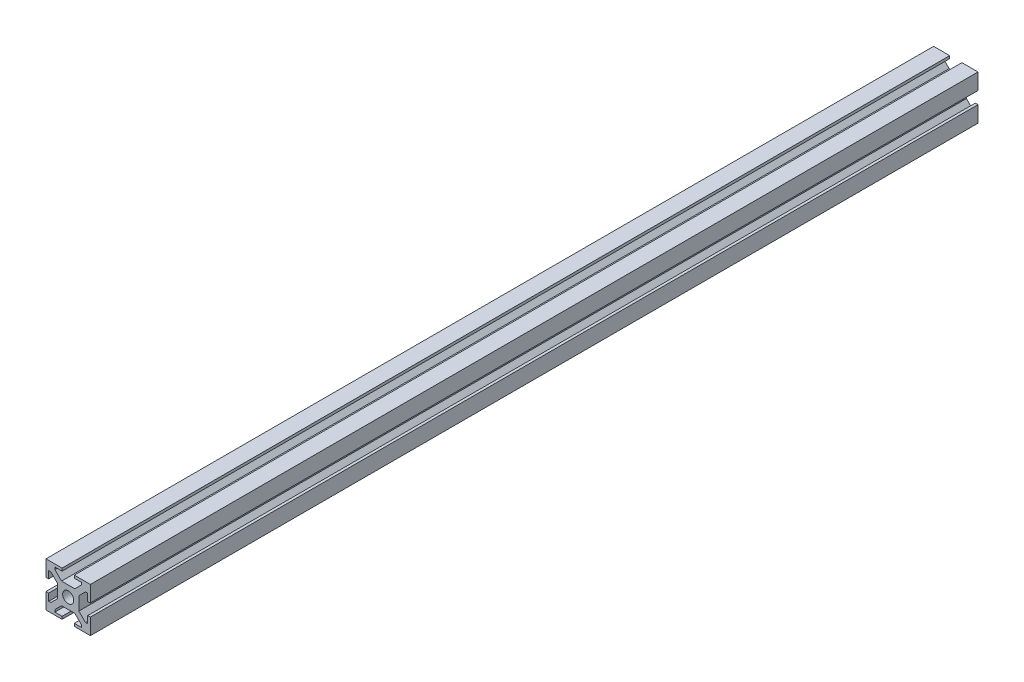
from build123d import *

# Parameters (mm, degrees)
ESQUISSE1_W             = 20
ESQUISSE1_H             = 20
BOSS_EXTRU_1_DEPTH      = 400
ESQUISSE2_W             = 1.2
ESQUISSE2_H             = 5.5
ESQUISSE2_W_2           = 5.5
ESQUISSE2_H_2           = 1.2
ENL_V_MAT_EXTRU_1_DEPTH = 401
ENL_V_MAT_EXTRU_2_DEPTH = 401
ESQUISSE4_R             = 2.5
ENL_V_MAT_EXTRU_3_DEPTH = 401


with BuildPart() as part:
    # Esquisse1 → Boss.-Extru.1 (new body)
    with BuildSketch(Plane.XY):
        with Locations((-12.505109137, -9.909560068)):
            Rectangle(ESQUISSE1_W, ESQUISSE1_H)
    extrude(amount=BOSS_EXTRU_1_DEPTH)

    # Esquisse2 → Enlèv. mat.-Extru.1 (cut, through all)
    with BuildSketch(Plane.XY.offset(400)):
        with Locations((-21.905109137, -9.909560068)):
            Rectangle(ESQUISSE2_W, ESQUISSE2_H)
        with Locations((-12.505109137, -0.509560068)):
            Rectangle(ESQUISSE2_W_2, ESQUISSE2_H_2)
        with Locations((-3.105109137, -9.909560068)):
            Rectangle(ESQUISSE2_W, ESQUISSE2_H)
        with Locations((-12.505109137, -19.309560068)):
            Rectangle(ESQUISSE2_W_2, ESQUISSE2_H_2)
    extrude(amount=-ENL_V_MAT_EXTRU_1_DEPTH, mode=Mode.SUBTRACT)

    # Esquisse3 → Enlèv. mat.-Extru.2 (cut, through all)
    with BuildSketch(Plane.XY.offset(400)):
        Polygon((-21.305109137, -15.909560068), (-20.305109137, -15.909560068), (-17.305109137, -12.909560068), (-17.305109137, -6.909560068), (-20.305109137, -3.909560068), (-21.305109137, -3.909560068), align=None)
        Polygon((-18.505109137, -1.109560068), (-6.505109137, -1.109560068), (-6.505109137, -2.109560068), (-9.505109137, -5.109560068), (-15.505109137, -5.109560068), (-18.505109137, -2.109560068), align=None)
        Polygon((-3.705109137, -3.909560068), (-4.705109137, -3.909560068), (-7.705109137, -6.909560068), (-7.705109137, -12.909560068), (-4.705109137, -15.909560068), (-3.705109137, -15.909560068), align=None)
        Polygon((-6.505109137, -18.709560068), (-18.505109137, -18.709560068), (-18.505109137, -17.709560068), (-15.505109137, -14.709560068), (-9.505109137, -14.709560068), (-6.505109137, -17.709560068), align=None)
    extrude(amount=-ENL_V_MAT_EXTRU_2_DEPTH, mode=Mode.SUBTRACT)

    # Esquisse4 → Enlèv. mat.-Extru.3 (cut, through all)
    with BuildSketch(Plane.XY.offset(400)):
        with Locations((-12.505109137, -9.909560068)):
            Circle(ESQUISSE4_R)
    extrude(amount=-ENL_V_MAT_EXTRU_3_DEPTH, mode=Mode.SUBTRACT)


solid = part.part
